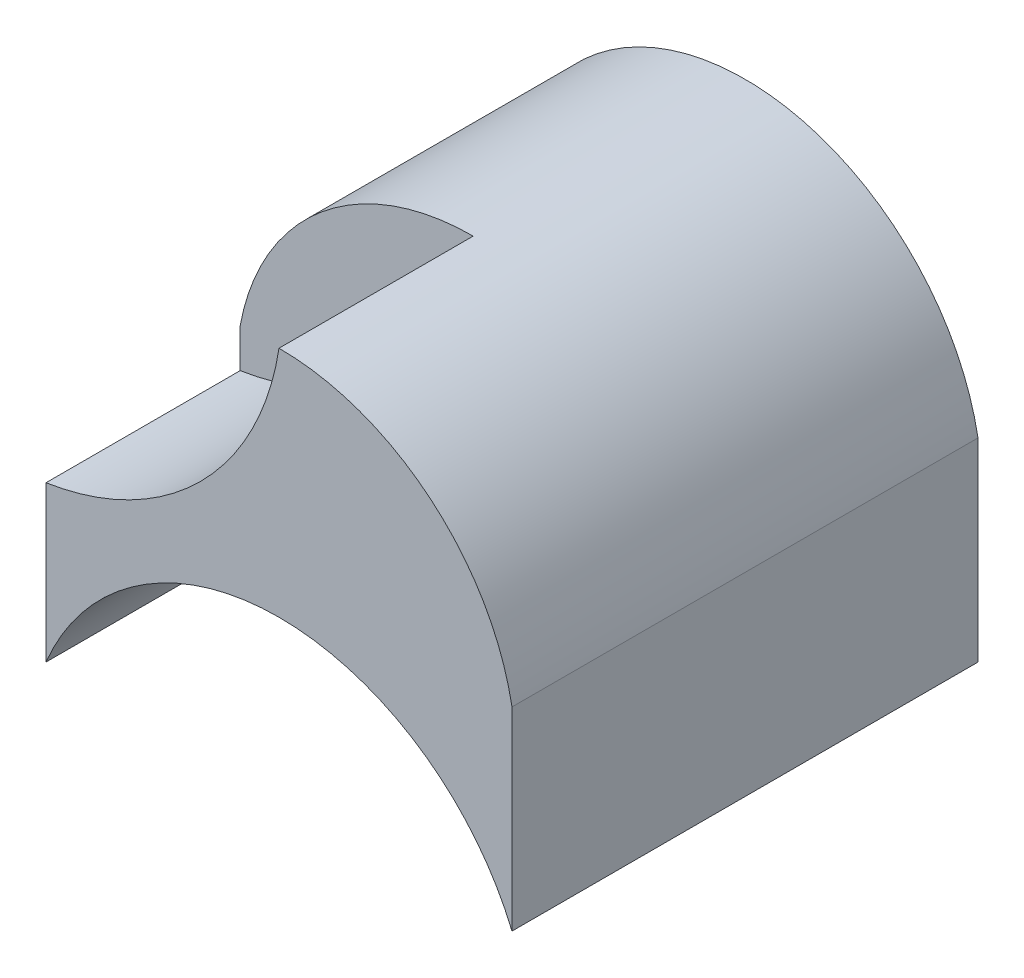
from build123d import *

# Parameters (mm, degrees)
SKETCH1_W           = 6
SKETCH1_H           = 6
BOSS_EXTRUDE1_DEPTH = 5
CUT_EXTRUDE4_DEPTH  = 12.5
CUT_EXTRUDE5_DEPTH  = 2.5


with BuildPart() as part:
    # Sketch1 → Boss-Extrude1 (new body)
    with BuildSketch(Plane(origin=(0, 0, 0), x_dir=(1, 0, 0), z_dir=(0, 1, 0))):
        Rectangle(SKETCH1_W, SKETCH1_H)
    extrude(amount=BOSS_EXTRUDE1_DEPTH)

    # Sketch5 → Cut-Extrude4 (cut)
    with BuildSketch(Plane.XY.offset(3)):
        with BuildLine():
            Line((-3, 5), (-3, 2.5))
            ThreePointArc((-3, 2.5), (-1.952562419, 4.293074903), (0, 5))
            Line((0, 5), (-3, 5))
        make_face()
        with BuildLine():
            ThreePointArc((0, 5), (1.952562419, 4.293074903), (3, 2.5))
            Line((3, 2.5), (3, 5))
            Line((3, 5), (0, 5))
        make_face()
        with BuildLine():
            ThreePointArc((-3, 0), (0, 2), (3, 0))
            Line((3, 0), (-3, 0))
        make_face()
    extrude(amount=-CUT_EXTRUDE4_DEPTH, mode=Mode.SUBTRACT)

    # Sketch6 → Cut-Extrude5 (cut)
    with BuildSketch(Plane.XY.offset(3)):
        with BuildLine():
            ThreePointArc((-3, 2), (-1.009831788, 3.009831788), (0, 5))
            ThreePointArc((0, 5), (-1.952562419, 4.293074903), (-3, 2.5))
            Line((-3, 2.5), (-3, 2))
        make_face()
    extrude(amount=-CUT_EXTRUDE5_DEPTH, mode=Mode.SUBTRACT)


solid = part.part
